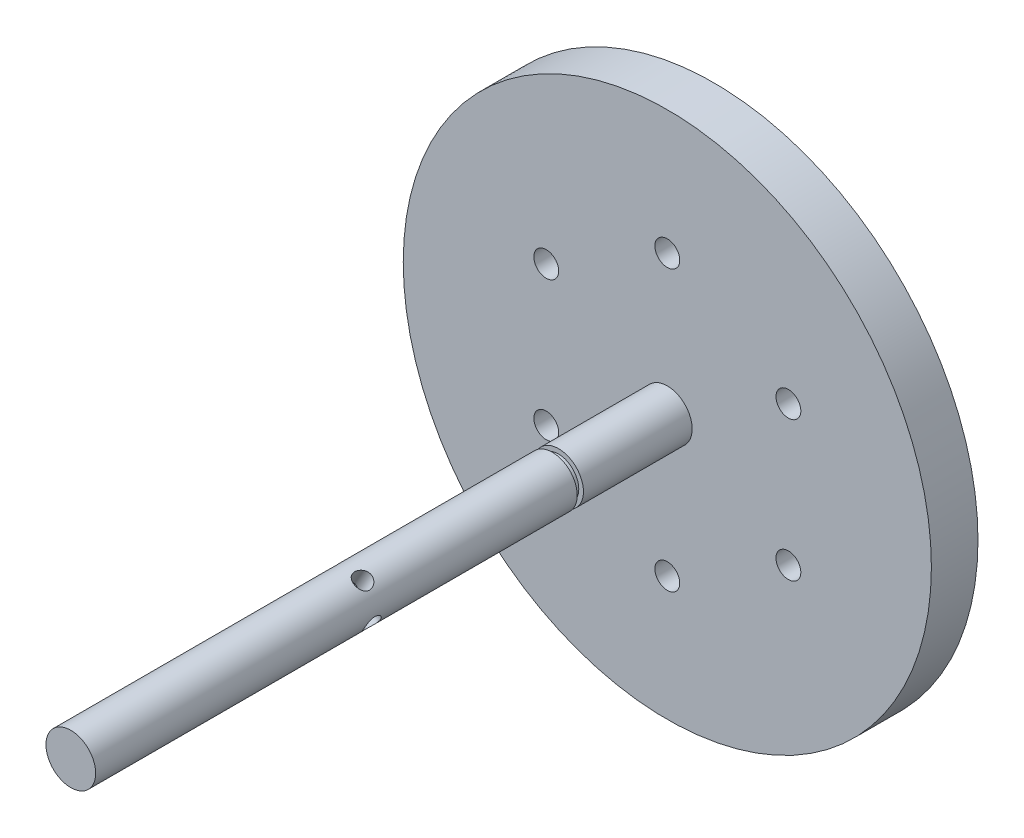
from build123d import *

# Parameters (mm, degrees)
F_8_0MM_DOWEL_HOLE1_D     = 8
F_8_0MM_DOWEL_HOLE1_DEPTH = 30
F_8_0MM_DOWEL_HOLE1_TIP   = 2.403442476
SKETCH10_R                = 2.75
CUT_EXTRUDE1_DEPTH        = 260
SKETCH11_R                = 2.75
CUT_EXTRUDE2_DEPTH        = 260
SKETCH12_R                = 4
CUT_EXTRUDE3_DEPTH        = 30


with BuildPart() as part:
    # Sketch1 → Revolve1 (revolve)
    with BuildSketch(Plane(origin=(0, 50, 0), x_dir=(1, 0, 0), z_dir=(0, 1, 0))):
        Polygon((85, -8), (0, -8), (0, -215), (8, -215), (8, -60), (6.5, -60), (6.5, -58), (8, -58), (8, -23), (85, -23), align=None)
    revolve(axis=Axis((0, 50, 8), (0, 0, 1)))

    # Ø8.0mm Dowel Hole1
    with Locations(Plane(origin=(0, 0, 8), x_dir=(-1, 0, 0), z_dir=(0, 0, -1))):
        with Locations((0, 95), (-38.97114317, 72.5), (-38.97114317, 27.5), (0, 5), (38.97114317, 27.5), (38.97114317, 72.5)):
            Hole(F_8_0MM_DOWEL_HOLE1_D / 2, depth=F_8_0MM_DOWEL_HOLE1_DEPTH)
            with Locations((0, 0, -(F_8_0MM_DOWEL_HOLE1_DEPTH + F_8_0MM_DOWEL_HOLE1_TIP / 2))):  # 118° drill point
                Cone(0, F_8_0MM_DOWEL_HOLE1_D / 2, F_8_0MM_DOWEL_HOLE1_TIP, mode=Mode.SUBTRACT)

    # Sketch10 → Cut-Extrude1 (cut)
    with BuildSketch(Plane(origin=(138.275547742, -79.833424711, 0), x_dir=(-0.5, -0.866025404, 0), z_dir=(0.866025404, -0.5, 0))):
        with Locations((-43.301270189, -125)):
            Circle(SKETCH10_R)
    extrude(amount=-CUT_EXTRUDE1_DEPTH, mode=Mode.SUBTRACT)

    # Sketch11 → Cut-Extrude2 (cut)
    with BuildSketch(Plane(origin=(46.091849247, 79.833424711, 0), x_dir=(0.866025404, -0.5, 0), z_dir=(0.5, 0.866025404, 0))):
        with Locations((-25, -125)):
            Circle(SKETCH11_R)
    extrude(amount=-CUT_EXTRUDE2_DEPTH, mode=Mode.SUBTRACT)

    # Sketch12 → Cut-Extrude3 (cut)
    with BuildSketch(Plane(origin=(0, 0, 8), x_dir=(-1, 0, 0), z_dir=(0, 0, -1))):
        with Locations((0, 50)):
            Circle(SKETCH12_R)
    extrude(amount=-CUT_EXTRUDE3_DEPTH, mode=Mode.SUBTRACT)


solid = part.part
